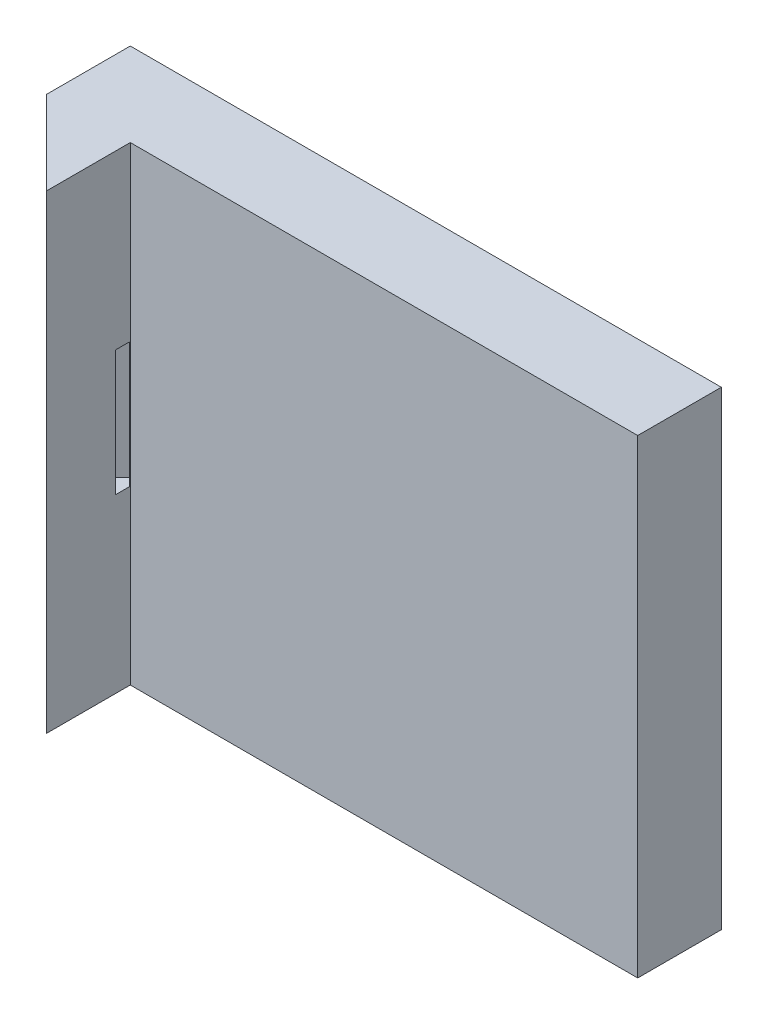
from build123d import *

# Parameters (mm, degrees)
SKETCH1_W           = 350
SKETCH1_H           = 56.2
BOSS_EXTRUDE1_DEPTH = 10
SKETCH2_W           = 56.2
SKETCH2_H           = 56.2
CUT_EXTRUDE1_DEPTH  = 5
SKETCH3_W           = 10
SKETCH3_H           = 56.2
BOSS_EXTRUDE2_DEPTH = 10
SKETCH4_W           = 10
SKETCH4_H           = 56.2
BOSS_EXTRUDE3_DEPTH = 10
CUT_EXTRUDE2_DEPTH  = 56.2
SKETCH6_W           = 10
SKETCH6_H           = 56.2
BOSS_EXTRUDE4_DEPTH = 10
SKETCH7_W           = 10
SKETCH7_H           = 56.2
BOSS_EXTRUDE5_DEPTH = 10
CUT_EXTRUDE3_DEPTH  = 56.2
SKETCH9_W           = 30
SKETCH9_H           = 30
CUT_EXTRUDE4_DEPTH  = 5
SKETCH10_R          = 3
CUT_EXTRUDE5_DEPTH  = 5
SKETCH11_W          = 2.5
SKETCH11_H          = 15
CUT_EXTRUDE6_DEPTH  = 7
SKETCH12_W          = 2.5
SKETCH12_H          = 15
CUT_EXTRUDE7_DEPTH  = 7
SKETCH14_W          = 279.3
SKETCH14_H          = 56.2
CUT_EXTRUDE10_DEPTH = 10
SKETCH15_W          = 20
SKETCH15_H          = 56.2
CUT_EXTRUDE11_DEPTH = 10


with BuildPart() as part:
    # Sketch1 → Boss-Extrude1 (new body)
    with BuildSketch(Plane.XY):
        Rectangle(SKETCH1_W, SKETCH1_H)
    extrude(amount=BOSS_EXTRUDE1_DEPTH)

    # Sketch2 → Cut-Extrude1 (cut)
    with BuildSketch(Plane.XY.offset(10)):
        Rectangle(SKETCH2_W, SKETCH2_H)
    extrude(amount=-CUT_EXTRUDE1_DEPTH, mode=Mode.SUBTRACT)

    # Sketch3 → Boss-Extrude2 (add)
    with BuildSketch(Plane(origin=(175, 0, 0), x_dir=(0, 0, -1), z_dir=(1, 0, 0))):
        with Locations((-5, 0)):
            Rectangle(SKETCH3_W, SKETCH3_H)
    extrude(amount=BOSS_EXTRUDE2_DEPTH)

    # Sketch4 → Boss-Extrude3 (add)
    with BuildSketch(Plane.XY.offset(10)):
        with Locations((180, 0)):
            Rectangle(SKETCH4_W, SKETCH4_H)
    extrude(amount=BOSS_EXTRUDE3_DEPTH)

    # Sketch5 → Cut-Extrude2 (cut)
    with BuildSketch(Plane(origin=(0, 28.1, 0), x_dir=(1, 0, 0), z_dir=(0, 1, 0))):
        Polygon((175, -20), (185, -10), (185, -20), align=None)
    extrude(amount=-CUT_EXTRUDE2_DEPTH, mode=Mode.SUBTRACT)

    # Sketch6 → Boss-Extrude4 (add)
    with BuildSketch(Plane.ZY.offset(175)):
        with Locations((5, 0)):
            Rectangle(SKETCH6_W, SKETCH6_H)
    extrude(amount=BOSS_EXTRUDE4_DEPTH)

    # Sketch7 → Boss-Extrude5 (add)
    with BuildSketch(Plane.XY.offset(10)):
        with Locations((-180, 0)):
            Rectangle(SKETCH7_W, SKETCH7_H)
    extrude(amount=BOSS_EXTRUDE5_DEPTH)

    # Sketch8 → Cut-Extrude3 (cut)
    with BuildSketch(Plane(origin=(0, 28.1, 0), x_dir=(1, 0, 0), z_dir=(0, 1, 0))):
        Polygon((-175, -20), (-185, -10), (-185, -20), align=None)
    extrude(amount=-CUT_EXTRUDE3_DEPTH, mode=Mode.SUBTRACT)

    # Sketch9 → Cut-Extrude4 (cut)
    with BuildSketch(Plane.XY.offset(5)):
        Rectangle(SKETCH9_W, SKETCH9_H)
    extrude(amount=-CUT_EXTRUDE4_DEPTH, mode=Mode.SUBTRACT)

    # Sketch10 → Cut-Extrude5 (cut)
    with BuildSketch(Plane.XY.offset(5)):
        with Locations((21.55, 21.55)):
            Circle(SKETCH10_R)
        with Locations((-21.55, -21.55)):
            Circle(SKETCH10_R)
        with Locations((-21.55, 21.55)):
            Circle(SKETCH10_R)
        with Locations((21.55, -21.55)):
            Circle(SKETCH10_R)
    extrude(amount=-CUT_EXTRUDE5_DEPTH, mode=Mode.SUBTRACT)

    # Sketch11 → Cut-Extrude6 (cut)
    with BuildSketch(Plane(origin=(97.5, 0, 97.5), x_dir=(0.7071067811865478, 0, -0.7071067811865472), z_dir=(0.7071067811865472, 0, 0.7071067811865478))):
        with Locations((116.672618896, 0)):
            Rectangle(SKETCH11_W, SKETCH11_H)
    extrude(amount=-CUT_EXTRUDE6_DEPTH, mode=Mode.SUBTRACT)

    # Sketch12 → Cut-Extrude7 (cut)
    with BuildSketch(Plane(origin=(-97.5, 0, 97.5), x_dir=(0.7071067811865478, 0, 0.7071067811865472), z_dir=(-0.7071067811865472, 0, 0.7071067811865478))):
        with Locations((-116.672618896, 0)):
            Rectangle(SKETCH12_W, SKETCH12_H)
    extrude(amount=-CUT_EXTRUDE7_DEPTH, mode=Mode.SUBTRACT)

    # Sketch14 → Cut-Extrude10 (cut)
    with BuildSketch(Plane.XY.offset(10)):
        with Locations((45.35, 0)):
            Rectangle(SKETCH14_W, SKETCH14_H)
    extrude(amount=-CUT_EXTRUDE10_DEPTH, mode=Mode.SUBTRACT)


with BuildPart() as body_2:
    # of the pieces the cut leaves, the one that is kept (cut_extrude10_keep)
    add(part.part.solids().sort_by_distance((-185, -28.1, 0))[0])

    # Sketch15 → Cut-Extrude11 (cut)
    with BuildSketch(Plane.XY.offset(10)):
        with Locations((-104.3, 0)):
            Rectangle(SKETCH15_W, SKETCH15_H)
    extrude(amount=-CUT_EXTRUDE11_DEPTH, mode=Mode.SUBTRACT)


solid = body_2.part
